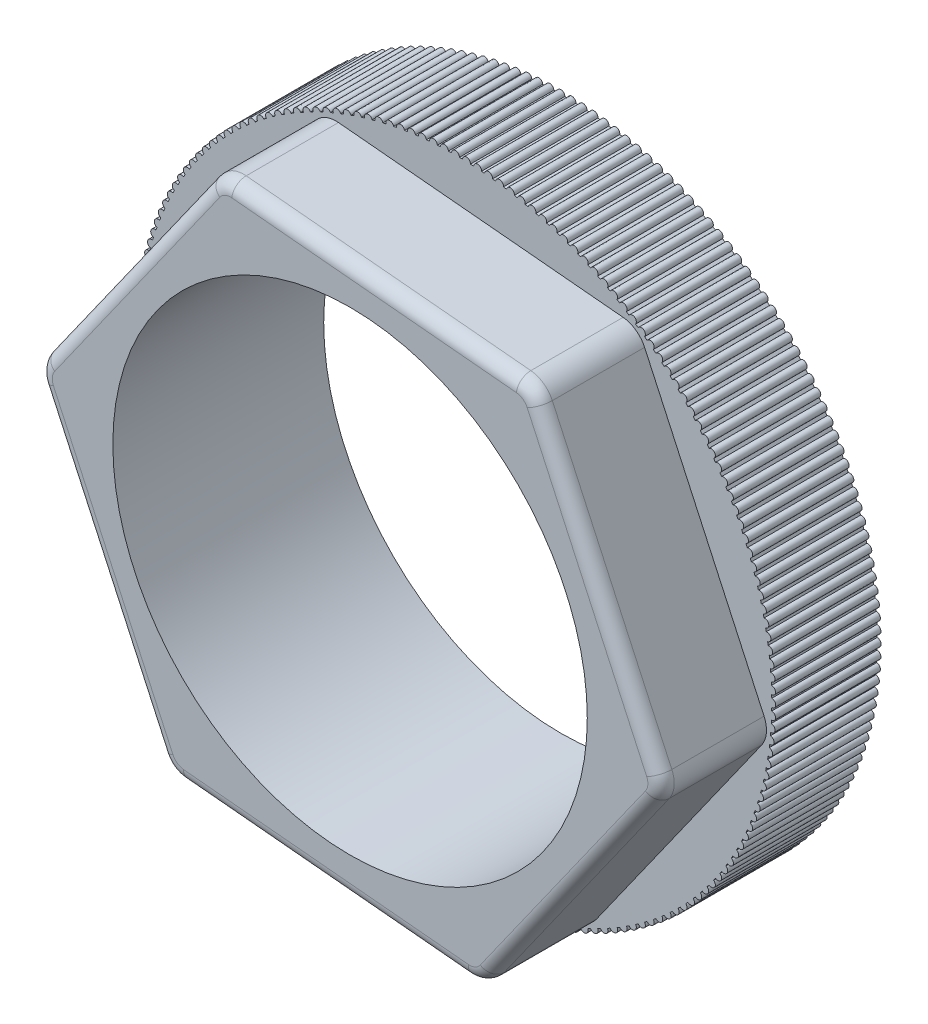
from build123d import *

# Parameters (mm, degrees)
CROQUIS1_R              = 12
CROQUIS1_R_2            = 9
SALIENTE_EXTRUIR1_DEPTH = 4
SALIENTE_EXTRUIR4_DEPTH = 4
CROQUIS3_R              = 9
SALIENTE_EXTRUIR5_DEPTH = 4
REDONDEO1_R             = 1
REDONDEO2_R             = 0.5


with BuildPart() as part:
    # Croquis1 → Saliente-Extruir1 (new body)
    with BuildSketch(Plane.XY):
        Circle(CROQUIS1_R)
        Circle(CROQUIS1_R_2, mode=Mode.SUBTRACT)
    extrude(amount=SALIENTE_EXTRUIR1_DEPTH)

    # Croquis2 → Saliente-Extruir4 (add)
    with BuildSketch(Plane.XY.offset(4)):
        with BuildLine():
            ThreePointArc((0.14999707, 11.9990625), (0, 12.15), (-0.14999707, 11.9990625))
            ThreePointArc((-0.14999707, 11.9990625), (0, 12), (0.14999707, 11.9990625))
        make_face()
        with BuildLine():
            ThreePointArc((0.568666938, 11.986518173), (0.41879396, 11.992689924), (0.268855546, 11.996987818))
            ThreePointArc((0.268855546, 11.996987818), (0.424028885, 12.142598548), (0.568666938, 11.986518173))
        make_face()
        with BuildLine():
            ThreePointArc((0.986643973, 11.95937012), (0.837077685, 11.970768603), (0.687380603, 11.980296654))
            ThreePointArc((0.687380603, 11.980296654), (0.847541156, 12.120403211), (0.986643973, 11.95937012))
        make_face()
        with BuildLine():
            ThreePointArc((1.403418934, 11.917651417), (1.254341559, 11.934262744), (1.105068193, 11.949009343))
            ThreePointArc((1.105068193, 11.949009343), (1.270020829, 12.083441029), (1.403418934, 11.917651417))
        make_face()
        with BuildLine():
            ThreePointArc((1.818484046, 11.861412891), (1.670077212, 11.883216825), (1.521409428, 11.903164006))
            ThreePointArc((1.521409428, 11.903164006), (1.690953177, 12.031757035), (1.818484046, 11.861412891))
        make_face()
        with BuildLine():
            ThreePointArc((2.231333615, 11.790723061), (2.083778132, 11.817693036), (1.935897059, 11.842816497))
            ThreePointArc((1.935897059, 11.842816497), (2.109825359, 11.965414199), (2.231333615, 11.790723061))
        make_face()
        with BuildLine():
            ThreePointArc((2.641464647, 11.705668051), (2.49494029, 11.737771209), (2.348026098, 11.76804034))
            ThreePointArc((2.348026098, 11.76804034), (2.526127043, 11.884493349), (2.641464647, 11.705668051))
        make_face()
        with BuildLine():
            ThreePointArc((3.048377462, 11.606351487), (2.903062747, 11.643548715), (2.757294429, 11.678926639))
            ThreePointArc((2.757294429, 11.678926639), (2.939351032, 11.789093074), (3.048377462, 11.606351487))
        make_face()
        with BuildLine():
            ThreePointArc((3.451576298, 11.492894373), (3.30764827, 11.535140351), (3.163203422, 11.575583964))
            ThreePointArc((3.163203422, 11.575583964), (3.348993873, 11.679329606), (3.451576298, 11.492894373))
        make_face()
        with BuildLine():
            ThreePointArc((3.85056992, 11.365434936), (3.708203932, 11.412678196), (3.565258538, 11.458138224))
            ThreePointArc((3.565258538, 11.458138224), (3.754556482, 11.555336673), (3.85056992, 11.365434936))
        make_face()
        with BuildLine():
            ThreePointArc((4.244872216, 11.224128468), (4.10424172, 11.276311449), (3.962969936, 11.326732507))
            ThreePointArc((3.962969936, 11.326732507), (4.155544741, 11.417265343), (4.244872216, 11.224128468))
        make_face()
        with BuildLine():
            ThreePointArc((4.634002789, 11.069147128), (4.495279121, 11.126206255), (4.355853066, 11.181526911))
            ThreePointArc((4.355853066, 11.181526911), (4.55147011, 11.265283833), (4.634002789, 11.069147128))
        make_face()
        with BuildLine():
            ThreePointArc((5.017487544, 10.900679738), (4.880839717, 10.962545492), (4.743429259, 11.022698348))
            ThreePointArc((4.743429259, 11.022698348), (4.941850213, 11.09957731), (5.017487544, 10.900679738))
        make_face()
        with BuildLine():
            ThreePointArc((5.394859262, 10.718931548), (5.260453761, 10.785528556), (5.125226315, 10.850440324))
            ThreePointArc((5.125226315, 10.850440324), (5.326209433, 10.920347663), (5.394859262, 10.718931548))
        make_face()
        with BuildLine():
            ThreePointArc((5.765658176, 10.524123992), (5.633658753, 10.595371114), (5.500779072, 10.66496271))
            ThreePointArc((5.500779072, 10.66496271), (5.704079488, 10.727813253), (5.765658176, 10.524123992))
        make_face()
        with BuildLine():
            ThreePointArc((6.129432523, 10.316494411), (6, 10.392304845), (5.869629977, 10.466491482))
            ThreePointArc((5.869629977, 10.466491482), (6.075, 10.522208656), (6.129432523, 10.316494411))
        make_face()
        with BuildLine():
            ThreePointArc((6.485739101, 10.096295772), (6.359031171, 10.176577154), (6.231329642, 10.255268446))
            ThreePointArc((6.231329642, 10.255268446), (6.43851906, 10.303784368), (6.485739101, 10.096295772))
        make_face()
        with BuildLine():
            ThreePointArc((6.834143805, 9.863796351), (6.710314842, 9.948450871), (6.585437391, 10.031550945))
            ThreePointArc((6.585437391, 10.031550945), (6.794193777, 10.072806507), (6.834143805, 9.863796351))
        make_face()
        with BuildLine():
            ThreePointArc((7.174222158, 9.619279413), (7.053423028, 9.708203932), (6.9315218, 9.795611545))
            ThreePointArc((6.9315218, 9.795611545), (7.141590815, 9.829556482), (7.174222158, 9.619279413))
        make_face()
        with BuildLine():
            ThreePointArc((7.505559826, 9.363042866), (7.387937704, 9.456129043), (7.269161217, 9.547737701))
            ThreePointArc((7.269161217, 9.547737701), (7.480286925, 9.574330656), (7.505559826, 9.363042866))
        make_face()
        with BuildLine():
            ThreePointArc((7.827753125, 9.095398892), (7.713451316, 9.192533317), (7.597944281, 9.288231409))
            ThreePointArc((7.597944281, 9.288231409), (7.809869458, 9.307439984), (7.827753125, 9.095398892))
        make_face()
        with BuildLine():
            ThreePointArc((8.140409513, 8.816673577), (8.029567276, 8.917737906), (7.91747042, 9.017408838))
            ThreePointArc((7.91747042, 9.017408838), (8.129936867, 9.02920963), (8.140409513, 8.816673577))
        make_face()
        with BuildLine():
            ThreePointArc((8.443148066, 8.527206503), (8.335900446, 8.632077604), (8.227350341, 8.735599943))
            ThreePointArc((8.227350341, 8.735599943), (8.440099201, 8.739978574), (8.443148066, 8.527206503))
        make_face()
        with BuildLine():
            ThreePointArc((8.735599943, 8.227350341), (8.632077604, 8.335900446), (8.527206503, 8.443148066))
            ThreePointArc((8.527206503, 8.443148066), (8.739978574, 8.440099201), (8.735599943, 8.227350341))
        make_face()
        with BuildLine():
            ThreePointArc((9.017408838, 7.91747042), (8.917737906, 8.029567276), (8.816673577, 8.140409513))
            ThreePointArc((8.816673577, 8.140409513), (9.02920963, 8.129936867), (9.017408838, 7.91747042))
        make_face()
        with BuildLine():
            ThreePointArc((9.288231409, 7.597944281), (9.192533317, 7.713451316), (9.095398892, 7.827753125))
            ThreePointArc((9.095398892, 7.827753125), (9.307439984, 7.809869458), (9.288231409, 7.597944281))
        make_face()
        with BuildLine():
            ThreePointArc((9.547737701, 7.269161217), (9.456129043, 7.387937704), (9.363042866, 7.505559826))
            ThreePointArc((9.363042866, 7.505559826), (9.574330656, 7.480286925), (9.547737701, 7.269161217))
        make_face()
        with BuildLine():
            ThreePointArc((9.795611545, 6.9315218), (9.708203932, 7.053423028), (9.619279413, 7.174222158))
            ThreePointArc((9.619279413, 7.174222158), (9.829556482, 7.141590815), (9.795611545, 6.9315218))
        make_face()
        with BuildLine():
            ThreePointArc((10.031550945, 6.585437391), (9.948450871, 6.710314842), (9.863796351, 6.834143805))
            ThreePointArc((9.863796351, 6.834143805), (10.072806507, 6.794193777), (10.031550945, 6.585437391))
        make_face()
        with BuildLine():
            ThreePointArc((10.255268446, 6.231329642), (10.176577154, 6.359031171), (10.096295772, 6.485739101))
            ThreePointArc((10.096295772, 6.485739101), (10.303784368, 6.43851906), (10.255268446, 6.231329642))
        make_face()
        with BuildLine():
            ThreePointArc((10.466491482, 5.869629977), (10.392304845, 6), (10.316494411, 6.129432523))
            ThreePointArc((10.316494411, 6.129432523), (10.522208656, 6.075), (10.466491482, 5.869629977))
        make_face()
        with BuildLine():
            ThreePointArc((10.66496271, 5.500779072), (10.595371114, 5.633658753), (10.524123992, 5.765658176))
            ThreePointArc((10.524123992, 5.765658176), (10.727813253, 5.704079488), (10.66496271, 5.500779072))
        make_face()
        with BuildLine():
            ThreePointArc((10.850440324, 5.125226315), (10.785528556, 5.260453761), (10.718931548, 5.394859262))
            ThreePointArc((10.718931548, 5.394859262), (10.920347663, 5.326209433), (10.850440324, 5.125226315))
        make_face()
        with BuildLine():
            ThreePointArc((11.022698348, 4.743429259), (10.962545492, 4.880839717), (10.900679738, 5.017487544))
            ThreePointArc((10.900679738, 5.017487544), (11.09957731, 4.941850213), (11.022698348, 4.743429259))
        make_face()
        with BuildLine():
            ThreePointArc((11.181526911, 4.355853066), (11.126206255, 4.495279121), (11.069147128, 4.634002789))
            ThreePointArc((11.069147128, 4.634002789), (11.265283833, 4.55147011), (11.181526911, 4.355853066))
        make_face()
        with BuildLine():
            ThreePointArc((11.326732507, 3.962969936), (11.276311449, 4.10424172), (11.224128468, 4.244872216))
            ThreePointArc((11.224128468, 4.244872216), (11.417265343, 4.155544741), (11.326732507, 3.962969936))
        make_face()
        with BuildLine():
            ThreePointArc((11.458138224, 3.565258538), (11.412678196, 3.708203932), (11.365434936, 3.85056992))
            ThreePointArc((11.365434936, 3.85056992), (11.555336673, 3.754556482), (11.458138224, 3.565258538))
        make_face()
        with BuildLine():
            ThreePointArc((11.575583964, 3.163203422), (11.535140351, 3.30764827), (11.492894373, 3.451576298))
            ThreePointArc((11.492894373, 3.451576298), (11.679329606, 3.348993873), (11.575583964, 3.163203422))
        make_face()
        with BuildLine():
            ThreePointArc((11.678926639, 2.757294429), (11.643548715, 2.903062747), (11.606351487, 3.048377462))
            ThreePointArc((11.606351487, 3.048377462), (11.789093074, 2.939351032), (11.678926639, 2.757294429))
        make_face()
        with BuildLine():
            ThreePointArc((11.76804034, 2.348026098), (11.737771209, 2.49494029), (11.705668051, 2.641464647))
            ThreePointArc((11.705668051, 2.641464647), (11.884493349, 2.526127043), (11.76804034, 2.348026098))
        make_face()
        with BuildLine():
            ThreePointArc((11.842816497, 1.935897059), (11.817693036, 2.083778132), (11.790723061, 2.231333615))
            ThreePointArc((11.790723061, 2.231333615), (11.965414199, 2.109825359), (11.842816497, 1.935897059))
        make_face()
        with BuildLine():
            ThreePointArc((11.903164006, 1.521409428), (11.883216825, 1.670077212), (11.861412891, 1.818484046))
            ThreePointArc((11.861412891, 1.818484046), (12.031757035, 1.690953177), (11.903164006, 1.521409428))
        make_face()
        with BuildLine():
            ThreePointArc((11.949009343, 1.105068193), (11.934262744, 1.254341559), (11.917651417, 1.403418934))
            ThreePointArc((11.917651417, 1.403418934), (12.083441029, 1.270020829), (11.949009343, 1.105068193))
        make_face()
        with BuildLine():
            ThreePointArc((11.980296654, 0.687380603), (11.970768603, 0.837077685), (11.95937012, 0.986643973))
            ThreePointArc((11.95937012, 0.986643973), (12.120403211, 0.847541156), (11.980296654, 0.687380603))
        make_face()
        with BuildLine():
            ThreePointArc((11.996987818, 0.268855546), (11.992689924, 0.41879396), (11.986518173, 0.568666938))
            ThreePointArc((11.986518173, 0.568666938), (12.142598548, 0.424028885), (11.996987818, 0.268855546))
        make_face()
        with BuildLine():
            ThreePointArc((11.9990625, -0.14999707), (12, 0), (11.9990625, 0.14999707))
            ThreePointArc((11.9990625, 0.14999707), (12.15, 0), (11.9990625, -0.14999707))
        make_face()
        with BuildLine():
            ThreePointArc((11.986518173, -0.568666938), (11.992689924, -0.41879396), (11.996987818, -0.268855546))
            ThreePointArc((11.996987818, -0.268855546), (12.142598548, -0.424028885), (11.986518173, -0.568666938))
        make_face()
        with BuildLine():
            ThreePointArc((11.95937012, -0.986643973), (11.970768603, -0.837077685), (11.980296654, -0.687380603))
            ThreePointArc((11.980296654, -0.687380603), (12.120403211, -0.847541156), (11.95937012, -0.986643973))
        make_face()
        with BuildLine():
            ThreePointArc((11.917651417, -1.403418934), (11.934262744, -1.254341559), (11.949009343, -1.105068193))
            ThreePointArc((11.949009343, -1.105068193), (12.083441029, -1.270020829), (11.917651417, -1.403418934))
        make_face()
        with BuildLine():
            ThreePointArc((11.861412891, -1.818484046), (11.883216825, -1.670077212), (11.903164006, -1.521409428))
            ThreePointArc((11.903164006, -1.521409428), (12.031757035, -1.690953177), (11.861412891, -1.818484046))
        make_face()
        with BuildLine():
            ThreePointArc((11.790723061, -2.231333615), (11.817693036, -2.083778132), (11.842816497, -1.935897059))
            ThreePointArc((11.842816497, -1.935897059), (11.965414199, -2.109825359), (11.790723061, -2.231333615))
        make_face()
        with BuildLine():
            ThreePointArc((11.705668051, -2.641464647), (11.737771209, -2.49494029), (11.76804034, -2.348026098))
            ThreePointArc((11.76804034, -2.348026098), (11.884493349, -2.526127043), (11.705668051, -2.641464647))
        make_face()
        with BuildLine():
            ThreePointArc((11.606351487, -3.048377462), (11.643548715, -2.903062747), (11.678926639, -2.757294429))
            ThreePointArc((11.678926639, -2.757294429), (11.789093074, -2.939351032), (11.606351487, -3.048377462))
        make_face()
        with BuildLine():
            ThreePointArc((11.492894373, -3.451576298), (11.535140351, -3.30764827), (11.575583964, -3.163203422))
            ThreePointArc((11.575583964, -3.163203422), (11.679329606, -3.348993873), (11.492894373, -3.451576298))
        make_face()
        with BuildLine():
            ThreePointArc((11.365434936, -3.85056992), (11.412678196, -3.708203932), (11.458138224, -3.565258538))
            ThreePointArc((11.458138224, -3.565258538), (11.555336673, -3.754556482), (11.365434936, -3.85056992))
        make_face()
        with BuildLine():
            ThreePointArc((11.224128468, -4.244872216), (11.276311449, -4.10424172), (11.326732507, -3.962969936))
            ThreePointArc((11.326732507, -3.962969936), (11.417265343, -4.155544741), (11.224128468, -4.244872216))
        make_face()
        with BuildLine():
            ThreePointArc((11.069147128, -4.634002789), (11.126206255, -4.495279121), (11.181526911, -4.355853066))
            ThreePointArc((11.181526911, -4.355853066), (11.265283833, -4.55147011), (11.069147128, -4.634002789))
        make_face()
        with BuildLine():
            ThreePointArc((10.900679738, -5.017487544), (10.962545492, -4.880839717), (11.022698348, -4.743429259))
            ThreePointArc((11.022698348, -4.743429259), (11.09957731, -4.941850213), (10.900679738, -5.017487544))
        make_face()
        with BuildLine():
            ThreePointArc((10.718931548, -5.394859262), (10.785528556, -5.260453761), (10.850440324, -5.125226315))
            ThreePointArc((10.850440324, -5.125226315), (10.920347663, -5.326209433), (10.718931548, -5.394859262))
        make_face()
        with BuildLine():
            ThreePointArc((10.524123992, -5.765658176), (10.595371114, -5.633658753), (10.66496271, -5.500779072))
            ThreePointArc((10.66496271, -5.500779072), (10.727813253, -5.704079488), (10.524123992, -5.765658176))
        make_face()
        with BuildLine():
            ThreePointArc((10.316494411, -6.129432523), (10.392304845, -6), (10.466491482, -5.869629977))
            ThreePointArc((10.466491482, -5.869629977), (10.522208656, -6.075), (10.316494411, -6.129432523))
        make_face()
        with BuildLine():
            ThreePointArc((10.096295772, -6.485739101), (10.176577154, -6.359031171), (10.255268446, -6.231329642))
            ThreePointArc((10.255268446, -6.231329642), (10.303784368, -6.43851906), (10.096295772, -6.485739101))
        make_face()
        with BuildLine():
            ThreePointArc((9.863796351, -6.834143805), (9.948450871, -6.710314842), (10.031550945, -6.585437391))
            ThreePointArc((10.031550945, -6.585437391), (10.072806507, -6.794193777), (9.863796351, -6.834143805))
        make_face()
        with BuildLine():
            ThreePointArc((9.619279413, -7.174222158), (9.708203932, -7.053423028), (9.795611545, -6.9315218))
            ThreePointArc((9.795611545, -6.9315218), (9.829556482, -7.141590815), (9.619279413, -7.174222158))
        make_face()
        with BuildLine():
            ThreePointArc((9.363042866, -7.505559826), (9.456129043, -7.387937704), (9.547737701, -7.269161217))
            ThreePointArc((9.547737701, -7.269161217), (9.574330656, -7.480286925), (9.363042866, -7.505559826))
        make_face()
        with BuildLine():
            ThreePointArc((9.095398892, -7.827753125), (9.192533317, -7.713451316), (9.288231409, -7.597944281))
            ThreePointArc((9.288231409, -7.597944281), (9.307439984, -7.809869458), (9.095398892, -7.827753125))
        make_face()
        with BuildLine():
            ThreePointArc((8.816673577, -8.140409513), (8.917737906, -8.029567276), (9.017408838, -7.91747042))
            ThreePointArc((9.017408838, -7.91747042), (9.02920963, -8.129936867), (8.816673577, -8.140409513))
        make_face()
        with BuildLine():
            ThreePointArc((8.527206503, -8.443148066), (8.632077604, -8.335900446), (8.735599943, -8.227350341))
            ThreePointArc((8.735599943, -8.227350341), (8.739978574, -8.440099201), (8.527206503, -8.443148066))
        make_face()
        with BuildLine():
            ThreePointArc((8.227350341, -8.735599943), (8.335900446, -8.632077604), (8.443148066, -8.527206503))
            ThreePointArc((8.443148066, -8.527206503), (8.440099201, -8.739978574), (8.227350341, -8.735599943))
        make_face()
        with BuildLine():
            ThreePointArc((7.91747042, -9.017408838), (8.029567276, -8.917737906), (8.140409513, -8.816673577))
            ThreePointArc((8.140409513, -8.816673577), (8.129936867, -9.02920963), (7.91747042, -9.017408838))
        make_face()
        with BuildLine():
            ThreePointArc((7.597944281, -9.288231409), (7.713451316, -9.192533317), (7.827753125, -9.095398892))
            ThreePointArc((7.827753125, -9.095398892), (7.809869458, -9.307439984), (7.597944281, -9.288231409))
        make_face()
        with BuildLine():
            ThreePointArc((7.269161217, -9.547737701), (7.387937704, -9.456129043), (7.505559826, -9.363042866))
            ThreePointArc((7.505559826, -9.363042866), (7.480286925, -9.574330656), (7.269161217, -9.547737701))
        make_face()
        with BuildLine():
            ThreePointArc((6.9315218, -9.795611545), (7.053423028, -9.708203932), (7.174222158, -9.619279413))
            ThreePointArc((7.174222158, -9.619279413), (7.141590815, -9.829556482), (6.9315218, -9.795611545))
        make_face()
        with BuildLine():
            ThreePointArc((6.585437391, -10.031550945), (6.710314842, -9.948450871), (6.834143805, -9.863796351))
            ThreePointArc((6.834143805, -9.863796351), (6.794193777, -10.072806507), (6.585437391, -10.031550945))
        make_face()
        with BuildLine():
            ThreePointArc((6.231329642, -10.255268446), (6.359031171, -10.176577154), (6.485739101, -10.096295772))
            ThreePointArc((6.485739101, -10.096295772), (6.43851906, -10.303784368), (6.231329642, -10.255268446))
        make_face()
        with BuildLine():
            ThreePointArc((5.869629977, -10.466491482), (6, -10.392304845), (6.129432523, -10.316494411))
            ThreePointArc((6.129432523, -10.316494411), (6.075, -10.522208656), (5.869629977, -10.466491482))
        make_face()
        with BuildLine():
            ThreePointArc((5.500779072, -10.66496271), (5.633658753, -10.595371114), (5.765658176, -10.524123992))
            ThreePointArc((5.765658176, -10.524123992), (5.704079488, -10.727813253), (5.500779072, -10.66496271))
        make_face()
        with BuildLine():
            ThreePointArc((5.125226315, -10.850440324), (5.260453761, -10.785528556), (5.394859262, -10.718931548))
            ThreePointArc((5.394859262, -10.718931548), (5.326209433, -10.920347663), (5.125226315, -10.850440324))
        make_face()
        with BuildLine():
            ThreePointArc((4.743429259, -11.022698348), (4.880839717, -10.962545492), (5.017487544, -10.900679738))
            ThreePointArc((5.017487544, -10.900679738), (4.941850213, -11.09957731), (4.743429259, -11.022698348))
        make_face()
        with BuildLine():
            ThreePointArc((4.355853066, -11.181526911), (4.495279121, -11.126206255), (4.634002789, -11.069147128))
            ThreePointArc((4.634002789, -11.069147128), (4.55147011, -11.265283833), (4.355853066, -11.181526911))
        make_face()
        with BuildLine():
            ThreePointArc((3.962969936, -11.326732507), (4.10424172, -11.276311449), (4.244872216, -11.224128468))
            ThreePointArc((4.244872216, -11.224128468), (4.155544741, -11.417265343), (3.962969936, -11.326732507))
        make_face()
        with BuildLine():
            ThreePointArc((3.565258538, -11.458138224), (3.708203932, -11.412678196), (3.85056992, -11.365434936))
            ThreePointArc((3.85056992, -11.365434936), (3.754556482, -11.555336673), (3.565258538, -11.458138224))
        make_face()
        with BuildLine():
            ThreePointArc((3.163203422, -11.575583964), (3.30764827, -11.535140351), (3.451576298, -11.492894373))
            ThreePointArc((3.451576298, -11.492894373), (3.348993873, -11.679329606), (3.163203422, -11.575583964))
        make_face()
        with BuildLine():
            ThreePointArc((2.757294429, -11.678926639), (2.903062747, -11.643548715), (3.048377462, -11.606351487))
            ThreePointArc((3.048377462, -11.606351487), (2.939351032, -11.789093074), (2.757294429, -11.678926639))
        make_face()
        with BuildLine():
            ThreePointArc((2.348026098, -11.76804034), (2.49494029, -11.737771209), (2.641464647, -11.705668051))
            ThreePointArc((2.641464647, -11.705668051), (2.526127043, -11.884493349), (2.348026098, -11.76804034))
        make_face()
        with BuildLine():
            ThreePointArc((1.935897059, -11.842816497), (2.083778132, -11.817693036), (2.231333615, -11.790723061))
            ThreePointArc((2.231333615, -11.790723061), (2.109825359, -11.965414199), (1.935897059, -11.842816497))
        make_face()
        with BuildLine():
            ThreePointArc((1.521409428, -11.903164006), (1.670077212, -11.883216825), (1.818484046, -11.861412891))
            ThreePointArc((1.818484046, -11.861412891), (1.690953177, -12.031757035), (1.521409428, -11.903164006))
        make_face()
        with BuildLine():
            ThreePointArc((1.105068193, -11.949009343), (1.254341559, -11.934262744), (1.403418934, -11.917651417))
            ThreePointArc((1.403418934, -11.917651417), (1.270020829, -12.083441029), (1.105068193, -11.949009343))
        make_face()
        with BuildLine():
            ThreePointArc((0.687380603, -11.980296654), (0.837077685, -11.970768603), (0.986643973, -11.95937012))
            ThreePointArc((0.986643973, -11.95937012), (0.847541156, -12.120403211), (0.687380603, -11.980296654))
        make_face()
        with BuildLine():
            ThreePointArc((0.268855546, -11.996987818), (0.41879396, -11.992689924), (0.568666938, -11.986518173))
            ThreePointArc((0.568666938, -11.986518173), (0.424028885, -12.142598548), (0.268855546, -11.996987818))
        make_face()
        with BuildLine():
            ThreePointArc((-0.14999707, -11.9990625), (0, -12), (0.14999707, -11.9990625))
            ThreePointArc((0.14999707, -11.9990625), (0, -12.15), (-0.14999707, -11.9990625))
        make_face()
        with BuildLine():
            ThreePointArc((-0.568666938, -11.986518173), (-0.41879396, -11.992689924), (-0.268855546, -11.996987818))
            ThreePointArc((-0.268855546, -11.996987818), (-0.424028885, -12.142598548), (-0.568666938, -11.986518173))
        make_face()
        with BuildLine():
            ThreePointArc((-0.986643973, -11.95937012), (-0.837077685, -11.970768603), (-0.687380603, -11.980296654))
            ThreePointArc((-0.687380603, -11.980296654), (-0.847541156, -12.120403211), (-0.986643973, -11.95937012))
        make_face()
        with BuildLine():
            ThreePointArc((-1.403418934, -11.917651417), (-1.254341559, -11.934262744), (-1.105068193, -11.949009343))
            ThreePointArc((-1.105068193, -11.949009343), (-1.270020829, -12.083441029), (-1.403418934, -11.917651417))
        make_face()
        with BuildLine():
            ThreePointArc((-1.818484046, -11.861412891), (-1.670077212, -11.883216825), (-1.521409428, -11.903164006))
            ThreePointArc((-1.521409428, -11.903164006), (-1.690953177, -12.031757035), (-1.818484046, -11.861412891))
        make_face()
        with BuildLine():
            ThreePointArc((-2.231333615, -11.790723061), (-2.083778132, -11.817693036), (-1.935897059, -11.842816497))
            ThreePointArc((-1.935897059, -11.842816497), (-2.109825359, -11.965414199), (-2.231333615, -11.790723061))
        make_face()
        with BuildLine():
            ThreePointArc((-2.641464647, -11.705668051), (-2.49494029, -11.737771209), (-2.348026098, -11.76804034))
            ThreePointArc((-2.348026098, -11.76804034), (-2.526127043, -11.884493349), (-2.641464647, -11.705668051))
        make_face()
        with BuildLine():
            ThreePointArc((-3.048377462, -11.606351487), (-2.903062747, -11.643548715), (-2.757294429, -11.678926639))
            ThreePointArc((-2.757294429, -11.678926639), (-2.939351032, -11.789093074), (-3.048377462, -11.606351487))
        make_face()
        with BuildLine():
            ThreePointArc((-3.451576298, -11.492894373), (-3.30764827, -11.535140351), (-3.163203422, -11.575583964))
            ThreePointArc((-3.163203422, -11.575583964), (-3.348993873, -11.679329606), (-3.451576298, -11.492894373))
        make_face()
        with BuildLine():
            ThreePointArc((-3.85056992, -11.365434936), (-3.708203932, -11.412678196), (-3.565258538, -11.458138224))
            ThreePointArc((-3.565258538, -11.458138224), (-3.754556482, -11.555336673), (-3.85056992, -11.365434936))
        make_face()
        with BuildLine():
            ThreePointArc((-4.244872216, -11.224128468), (-4.10424172, -11.276311449), (-3.962969936, -11.326732507))
            ThreePointArc((-3.962969936, -11.326732507), (-4.155544741, -11.417265343), (-4.244872216, -11.224128468))
        make_face()
        with BuildLine():
            ThreePointArc((-4.634002789, -11.069147128), (-4.495279121, -11.126206255), (-4.355853066, -11.181526911))
            ThreePointArc((-4.355853066, -11.181526911), (-4.55147011, -11.265283833), (-4.634002789, -11.069147128))
        make_face()
        with BuildLine():
            ThreePointArc((-5.017487544, -10.900679738), (-4.880839717, -10.962545492), (-4.743429259, -11.022698348))
            ThreePointArc((-4.743429259, -11.022698348), (-4.941850213, -11.09957731), (-5.017487544, -10.900679738))
        make_face()
        with BuildLine():
            ThreePointArc((-5.394859262, -10.718931548), (-5.260453761, -10.785528556), (-5.125226315, -10.850440324))
            ThreePointArc((-5.125226315, -10.850440324), (-5.326209433, -10.920347663), (-5.394859262, -10.718931548))
        make_face()
        with BuildLine():
            ThreePointArc((-5.765658176, -10.524123992), (-5.633658753, -10.595371114), (-5.500779072, -10.66496271))
            ThreePointArc((-5.500779072, -10.66496271), (-5.704079488, -10.727813253), (-5.765658176, -10.524123992))
        make_face()
        with BuildLine():
            ThreePointArc((-6.129432523, -10.316494411), (-6, -10.392304845), (-5.869629977, -10.466491482))
            ThreePointArc((-5.869629977, -10.466491482), (-6.075, -10.522208656), (-6.129432523, -10.316494411))
        make_face()
        with BuildLine():
            ThreePointArc((-6.485739101, -10.096295772), (-6.359031171, -10.176577154), (-6.231329642, -10.255268446))
            ThreePointArc((-6.231329642, -10.255268446), (-6.43851906, -10.303784368), (-6.485739101, -10.096295772))
        make_face()
        with BuildLine():
            ThreePointArc((-6.834143805, -9.863796351), (-6.710314842, -9.948450871), (-6.585437391, -10.031550945))
            ThreePointArc((-6.585437391, -10.031550945), (-6.794193777, -10.072806507), (-6.834143805, -9.863796351))
        make_face()
        with BuildLine():
            ThreePointArc((-7.174222158, -9.619279413), (-7.053423028, -9.708203932), (-6.9315218, -9.795611545))
            ThreePointArc((-6.9315218, -9.795611545), (-7.141590815, -9.829556482), (-7.174222158, -9.619279413))
        make_face()
        with BuildLine():
            ThreePointArc((-7.505559826, -9.363042866), (-7.387937704, -9.456129043), (-7.269161217, -9.547737701))
            ThreePointArc((-7.269161217, -9.547737701), (-7.480286925, -9.574330656), (-7.505559826, -9.363042866))
        make_face()
        with BuildLine():
            ThreePointArc((-7.827753125, -9.095398892), (-7.713451316, -9.192533317), (-7.597944281, -9.288231409))
            ThreePointArc((-7.597944281, -9.288231409), (-7.809869458, -9.307439984), (-7.827753125, -9.095398892))
        make_face()
        with BuildLine():
            ThreePointArc((-8.140409513, -8.816673577), (-8.029567276, -8.917737906), (-7.91747042, -9.017408838))
            ThreePointArc((-7.91747042, -9.017408838), (-8.129936867, -9.02920963), (-8.140409513, -8.816673577))
        make_face()
        with BuildLine():
            ThreePointArc((-8.443148066, -8.527206503), (-8.335900446, -8.632077604), (-8.227350341, -8.735599943))
            ThreePointArc((-8.227350341, -8.735599943), (-8.440099201, -8.739978574), (-8.443148066, -8.527206503))
        make_face()
        with BuildLine():
            ThreePointArc((-8.735599943, -8.227350341), (-8.632077604, -8.335900446), (-8.527206503, -8.443148066))
            ThreePointArc((-8.527206503, -8.443148066), (-8.739978574, -8.440099201), (-8.735599943, -8.227350341))
        make_face()
        with BuildLine():
            ThreePointArc((-9.017408838, -7.91747042), (-8.917737906, -8.029567276), (-8.816673577, -8.140409513))
            ThreePointArc((-8.816673577, -8.140409513), (-9.02920963, -8.129936867), (-9.017408838, -7.91747042))
        make_face()
        with BuildLine():
            ThreePointArc((-9.288231409, -7.597944281), (-9.192533317, -7.713451316), (-9.095398892, -7.827753125))
            ThreePointArc((-9.095398892, -7.827753125), (-9.307439984, -7.809869458), (-9.288231409, -7.597944281))
        make_face()
        with BuildLine():
            ThreePointArc((-9.547737701, -7.269161217), (-9.456129043, -7.387937704), (-9.363042866, -7.505559826))
            ThreePointArc((-9.363042866, -7.505559826), (-9.574330656, -7.480286925), (-9.547737701, -7.269161217))
        make_face()
        with BuildLine():
            ThreePointArc((-9.795611545, -6.9315218), (-9.708203932, -7.053423028), (-9.619279413, -7.174222158))
            ThreePointArc((-9.619279413, -7.174222158), (-9.829556482, -7.141590815), (-9.795611545, -6.9315218))
        make_face()
        with BuildLine():
            ThreePointArc((-10.031550945, -6.585437391), (-9.948450871, -6.710314842), (-9.863796351, -6.834143805))
            ThreePointArc((-9.863796351, -6.834143805), (-10.072806507, -6.794193777), (-10.031550945, -6.585437391))
        make_face()
        with BuildLine():
            ThreePointArc((-10.255268446, -6.231329642), (-10.176577154, -6.359031171), (-10.096295772, -6.485739101))
            ThreePointArc((-10.096295772, -6.485739101), (-10.303784368, -6.43851906), (-10.255268446, -6.231329642))
        make_face()
        with BuildLine():
            ThreePointArc((-10.466491482, -5.869629977), (-10.392304845, -6), (-10.316494411, -6.129432523))
            ThreePointArc((-10.316494411, -6.129432523), (-10.522208656, -6.075), (-10.466491482, -5.869629977))
        make_face()
        with BuildLine():
            ThreePointArc((-10.66496271, -5.500779072), (-10.595371114, -5.633658753), (-10.524123992, -5.765658176))
            ThreePointArc((-10.524123992, -5.765658176), (-10.727813253, -5.704079488), (-10.66496271, -5.500779072))
        make_face()
        with BuildLine():
            ThreePointArc((-10.850440324, -5.125226315), (-10.785528556, -5.260453761), (-10.718931548, -5.394859262))
            ThreePointArc((-10.718931548, -5.394859262), (-10.920347663, -5.326209433), (-10.850440324, -5.125226315))
        make_face()
        with BuildLine():
            ThreePointArc((-11.022698348, -4.743429259), (-10.962545492, -4.880839717), (-10.900679738, -5.017487544))
            ThreePointArc((-10.900679738, -5.017487544), (-11.09957731, -4.941850213), (-11.022698348, -4.743429259))
        make_face()
        with BuildLine():
            ThreePointArc((-11.181526911, -4.355853066), (-11.126206255, -4.495279121), (-11.069147128, -4.634002789))
            ThreePointArc((-11.069147128, -4.634002789), (-11.265283833, -4.55147011), (-11.181526911, -4.355853066))
        make_face()
        with BuildLine():
            ThreePointArc((-11.326732507, -3.962969936), (-11.276311449, -4.10424172), (-11.224128468, -4.244872216))
            ThreePointArc((-11.224128468, -4.244872216), (-11.417265343, -4.155544741), (-11.326732507, -3.962969936))
        make_face()
        with BuildLine():
            ThreePointArc((-11.458138224, -3.565258538), (-11.412678196, -3.708203932), (-11.365434936, -3.85056992))
            ThreePointArc((-11.365434936, -3.85056992), (-11.555336673, -3.754556482), (-11.458138224, -3.565258538))
        make_face()
        with BuildLine():
            ThreePointArc((-11.575583964, -3.163203422), (-11.535140351, -3.30764827), (-11.492894373, -3.451576298))
            ThreePointArc((-11.492894373, -3.451576298), (-11.679329606, -3.348993873), (-11.575583964, -3.163203422))
        make_face()
        with BuildLine():
            ThreePointArc((-11.678926639, -2.757294429), (-11.643548715, -2.903062747), (-11.606351487, -3.048377462))
            ThreePointArc((-11.606351487, -3.048377462), (-11.789093074, -2.939351032), (-11.678926639, -2.757294429))
        make_face()
        with BuildLine():
            ThreePointArc((-11.76804034, -2.348026098), (-11.737771209, -2.49494029), (-11.705668051, -2.641464647))
            ThreePointArc((-11.705668051, -2.641464647), (-11.884493349, -2.526127043), (-11.76804034, -2.348026098))
        make_face()
        with BuildLine():
            ThreePointArc((-11.842816497, -1.935897059), (-11.817693036, -2.083778132), (-11.790723061, -2.231333615))
            ThreePointArc((-11.790723061, -2.231333615), (-11.965414199, -2.109825359), (-11.842816497, -1.935897059))
        make_face()
        with BuildLine():
            ThreePointArc((-11.903164006, -1.521409428), (-11.883216825, -1.670077212), (-11.861412891, -1.818484046))
            ThreePointArc((-11.861412891, -1.818484046), (-12.031757035, -1.690953177), (-11.903164006, -1.521409428))
        make_face()
        with BuildLine():
            ThreePointArc((-11.949009343, -1.105068193), (-11.934262744, -1.254341559), (-11.917651417, -1.403418934))
            ThreePointArc((-11.917651417, -1.403418934), (-12.083441029, -1.270020829), (-11.949009343, -1.105068193))
        make_face()
        with BuildLine():
            ThreePointArc((-11.980296654, -0.687380603), (-11.970768603, -0.837077685), (-11.95937012, -0.986643973))
            ThreePointArc((-11.95937012, -0.986643973), (-12.120403211, -0.847541156), (-11.980296654, -0.687380603))
        make_face()
        with BuildLine():
            ThreePointArc((-11.996987818, -0.268855546), (-11.992689924, -0.41879396), (-11.986518173, -0.568666938))
            ThreePointArc((-11.986518173, -0.568666938), (-12.142598548, -0.424028885), (-11.996987818, -0.268855546))
        make_face()
        with BuildLine():
            ThreePointArc((-11.9990625, 0.14999707), (-12, 0), (-11.9990625, -0.14999707))
            ThreePointArc((-11.9990625, -0.14999707), (-12.15, 0), (-11.9990625, 0.14999707))
        make_face()
        with BuildLine():
            ThreePointArc((-11.986518173, 0.568666938), (-11.992689924, 0.41879396), (-11.996987818, 0.268855546))
            ThreePointArc((-11.996987818, 0.268855546), (-12.142598548, 0.424028885), (-11.986518173, 0.568666938))
        make_face()
        with BuildLine():
            ThreePointArc((-11.95937012, 0.986643973), (-11.970768603, 0.837077685), (-11.980296654, 0.687380603))
            ThreePointArc((-11.980296654, 0.687380603), (-12.120403211, 0.847541156), (-11.95937012, 0.986643973))
        make_face()
        with BuildLine():
            ThreePointArc((-11.917651417, 1.403418934), (-11.934262744, 1.254341559), (-11.949009343, 1.105068193))
            ThreePointArc((-11.949009343, 1.105068193), (-12.083441029, 1.270020829), (-11.917651417, 1.403418934))
        make_face()
        with BuildLine():
            ThreePointArc((-11.861412891, 1.818484046), (-11.883216825, 1.670077212), (-11.903164006, 1.521409428))
            ThreePointArc((-11.903164006, 1.521409428), (-12.031757035, 1.690953177), (-11.861412891, 1.818484046))
        make_face()
        with BuildLine():
            ThreePointArc((-11.790723061, 2.231333615), (-11.817693036, 2.083778132), (-11.842816497, 1.935897059))
            ThreePointArc((-11.842816497, 1.935897059), (-11.965414199, 2.109825359), (-11.790723061, 2.231333615))
        make_face()
        with BuildLine():
            ThreePointArc((-11.705668051, 2.641464647), (-11.737771209, 2.49494029), (-11.76804034, 2.348026098))
            ThreePointArc((-11.76804034, 2.348026098), (-11.884493349, 2.526127043), (-11.705668051, 2.641464647))
        make_face()
        with BuildLine():
            ThreePointArc((-11.606351487, 3.048377462), (-11.643548715, 2.903062747), (-11.678926639, 2.757294429))
            ThreePointArc((-11.678926639, 2.757294429), (-11.789093074, 2.939351032), (-11.606351487, 3.048377462))
        make_face()
        with BuildLine():
            ThreePointArc((-11.492894373, 3.451576298), (-11.535140351, 3.30764827), (-11.575583964, 3.163203422))
            ThreePointArc((-11.575583964, 3.163203422), (-11.679329606, 3.348993873), (-11.492894373, 3.451576298))
        make_face()
        with BuildLine():
            ThreePointArc((-11.365434936, 3.85056992), (-11.412678196, 3.708203932), (-11.458138224, 3.565258538))
            ThreePointArc((-11.458138224, 3.565258538), (-11.555336673, 3.754556482), (-11.365434936, 3.85056992))
        make_face()
        with BuildLine():
            ThreePointArc((-11.224128468, 4.244872216), (-11.276311449, 4.10424172), (-11.326732507, 3.962969936))
            ThreePointArc((-11.326732507, 3.962969936), (-11.417265343, 4.155544741), (-11.224128468, 4.244872216))
        make_face()
        with BuildLine():
            ThreePointArc((-11.069147128, 4.634002789), (-11.126206255, 4.495279121), (-11.181526911, 4.355853066))
            ThreePointArc((-11.181526911, 4.355853066), (-11.265283833, 4.55147011), (-11.069147128, 4.634002789))
        make_face()
        with BuildLine():
            ThreePointArc((-10.900679738, 5.017487544), (-10.962545492, 4.880839717), (-11.022698348, 4.743429259))
            ThreePointArc((-11.022698348, 4.743429259), (-11.09957731, 4.941850213), (-10.900679738, 5.017487544))
        make_face()
        with BuildLine():
            ThreePointArc((-10.718931548, 5.394859262), (-10.785528556, 5.260453761), (-10.850440324, 5.125226315))
            ThreePointArc((-10.850440324, 5.125226315), (-10.920347663, 5.326209433), (-10.718931548, 5.394859262))
        make_face()
        with BuildLine():
            ThreePointArc((-10.524123992, 5.765658176), (-10.595371114, 5.633658753), (-10.66496271, 5.500779072))
            ThreePointArc((-10.66496271, 5.500779072), (-10.727813253, 5.704079488), (-10.524123992, 5.765658176))
        make_face()
        with BuildLine():
            ThreePointArc((-10.316494411, 6.129432523), (-10.392304845, 6), (-10.466491482, 5.869629977))
            ThreePointArc((-10.466491482, 5.869629977), (-10.522208656, 6.075), (-10.316494411, 6.129432523))
        make_face()
        with BuildLine():
            ThreePointArc((-10.096295772, 6.485739101), (-10.176577154, 6.359031171), (-10.255268446, 6.231329642))
            ThreePointArc((-10.255268446, 6.231329642), (-10.303784368, 6.43851906), (-10.096295772, 6.485739101))
        make_face()
        with BuildLine():
            ThreePointArc((-9.863796351, 6.834143805), (-9.948450871, 6.710314842), (-10.031550945, 6.585437391))
            ThreePointArc((-10.031550945, 6.585437391), (-10.072806507, 6.794193777), (-9.863796351, 6.834143805))
        make_face()
        with BuildLine():
            ThreePointArc((-9.619279413, 7.174222158), (-9.708203932, 7.053423028), (-9.795611545, 6.9315218))
            ThreePointArc((-9.795611545, 6.9315218), (-9.829556482, 7.141590815), (-9.619279413, 7.174222158))
        make_face()
        with BuildLine():
            ThreePointArc((-9.363042866, 7.505559826), (-9.456129043, 7.387937704), (-9.547737701, 7.269161217))
            ThreePointArc((-9.547737701, 7.269161217), (-9.574330656, 7.480286925), (-9.363042866, 7.505559826))
        make_face()
        with BuildLine():
            ThreePointArc((-9.095398892, 7.827753125), (-9.192533317, 7.713451316), (-9.288231409, 7.597944281))
            ThreePointArc((-9.288231409, 7.597944281), (-9.307439984, 7.809869458), (-9.095398892, 7.827753125))
        make_face()
        with BuildLine():
            ThreePointArc((-8.816673577, 8.140409513), (-8.917737906, 8.029567276), (-9.017408838, 7.91747042))
            ThreePointArc((-9.017408838, 7.91747042), (-9.02920963, 8.129936867), (-8.816673577, 8.140409513))
        make_face()
        with BuildLine():
            ThreePointArc((-8.527206503, 8.443148066), (-8.632077604, 8.335900446), (-8.735599943, 8.227350341))
            ThreePointArc((-8.735599943, 8.227350341), (-8.739978574, 8.440099201), (-8.527206503, 8.443148066))
        make_face()
        with BuildLine():
            ThreePointArc((-8.227350341, 8.735599943), (-8.335900446, 8.632077604), (-8.443148066, 8.527206503))
            ThreePointArc((-8.443148066, 8.527206503), (-8.440099201, 8.739978574), (-8.227350341, 8.735599943))
        make_face()
        with BuildLine():
            ThreePointArc((-7.91747042, 9.017408838), (-8.029567276, 8.917737906), (-8.140409513, 8.816673577))
            ThreePointArc((-8.140409513, 8.816673577), (-8.129936867, 9.02920963), (-7.91747042, 9.017408838))
        make_face()
        with BuildLine():
            ThreePointArc((-7.597944281, 9.288231409), (-7.713451316, 9.192533317), (-7.827753125, 9.095398892))
            ThreePointArc((-7.827753125, 9.095398892), (-7.809869458, 9.307439984), (-7.597944281, 9.288231409))
        make_face()
        with BuildLine():
            ThreePointArc((-7.269161217, 9.547737701), (-7.387937704, 9.456129043), (-7.505559826, 9.363042866))
            ThreePointArc((-7.505559826, 9.363042866), (-7.480286925, 9.574330656), (-7.269161217, 9.547737701))
        make_face()
        with BuildLine():
            ThreePointArc((-6.9315218, 9.795611545), (-7.053423028, 9.708203932), (-7.174222158, 9.619279413))
            ThreePointArc((-7.174222158, 9.619279413), (-7.141590815, 9.829556482), (-6.9315218, 9.795611545))
        make_face()
        with BuildLine():
            ThreePointArc((-6.585437391, 10.031550945), (-6.710314842, 9.948450871), (-6.834143805, 9.863796351))
            ThreePointArc((-6.834143805, 9.863796351), (-6.794193777, 10.072806507), (-6.585437391, 10.031550945))
        make_face()
        with BuildLine():
            ThreePointArc((-6.231329642, 10.255268446), (-6.359031171, 10.176577154), (-6.485739101, 10.096295772))
            ThreePointArc((-6.485739101, 10.096295772), (-6.43851906, 10.303784368), (-6.231329642, 10.255268446))
        make_face()
        with BuildLine():
            ThreePointArc((-5.869629977, 10.466491482), (-6, 10.392304845), (-6.129432523, 10.316494411))
            ThreePointArc((-6.129432523, 10.316494411), (-6.075, 10.522208656), (-5.869629977, 10.466491482))
        make_face()
        with BuildLine():
            ThreePointArc((-5.500779072, 10.66496271), (-5.633658753, 10.595371114), (-5.765658176, 10.524123992))
            ThreePointArc((-5.765658176, 10.524123992), (-5.704079488, 10.727813253), (-5.500779072, 10.66496271))
        make_face()
        with BuildLine():
            ThreePointArc((-5.125226315, 10.850440324), (-5.260453761, 10.785528556), (-5.394859262, 10.718931548))
            ThreePointArc((-5.394859262, 10.718931548), (-5.326209433, 10.920347663), (-5.125226315, 10.850440324))
        make_face()
        with BuildLine():
            ThreePointArc((-4.743429259, 11.022698348), (-4.880839717, 10.962545492), (-5.017487544, 10.900679738))
            ThreePointArc((-5.017487544, 10.900679738), (-4.941850213, 11.09957731), (-4.743429259, 11.022698348))
        make_face()
        with BuildLine():
            ThreePointArc((-4.355853066, 11.181526911), (-4.495279121, 11.126206255), (-4.634002789, 11.069147128))
            ThreePointArc((-4.634002789, 11.069147128), (-4.55147011, 11.265283833), (-4.355853066, 11.181526911))
        make_face()
        with BuildLine():
            ThreePointArc((-3.962969936, 11.326732507), (-4.10424172, 11.276311449), (-4.244872216, 11.224128468))
            ThreePointArc((-4.244872216, 11.224128468), (-4.155544741, 11.417265343), (-3.962969936, 11.326732507))
        make_face()
        with BuildLine():
            ThreePointArc((-3.565258538, 11.458138224), (-3.708203932, 11.412678196), (-3.85056992, 11.365434936))
            ThreePointArc((-3.85056992, 11.365434936), (-3.754556482, 11.555336673), (-3.565258538, 11.458138224))
        make_face()
        with BuildLine():
            ThreePointArc((-3.163203422, 11.575583964), (-3.30764827, 11.535140351), (-3.451576298, 11.492894373))
            ThreePointArc((-3.451576298, 11.492894373), (-3.348993873, 11.679329606), (-3.163203422, 11.575583964))
        make_face()
        with BuildLine():
            ThreePointArc((-2.757294429, 11.678926639), (-2.903062747, 11.643548715), (-3.048377462, 11.606351487))
            ThreePointArc((-3.048377462, 11.606351487), (-2.939351032, 11.789093074), (-2.757294429, 11.678926639))
        make_face()
        with BuildLine():
            ThreePointArc((-2.348026098, 11.76804034), (-2.49494029, 11.737771209), (-2.641464647, 11.705668051))
            ThreePointArc((-2.641464647, 11.705668051), (-2.526127043, 11.884493349), (-2.348026098, 11.76804034))
        make_face()
        with BuildLine():
            ThreePointArc((-1.935897059, 11.842816497), (-2.083778132, 11.817693036), (-2.231333615, 11.790723061))
            ThreePointArc((-2.231333615, 11.790723061), (-2.109825359, 11.965414199), (-1.935897059, 11.842816497))
        make_face()
        with BuildLine():
            ThreePointArc((-1.521409428, 11.903164006), (-1.670077212, 11.883216825), (-1.818484046, 11.861412891))
            ThreePointArc((-1.818484046, 11.861412891), (-1.690953177, 12.031757035), (-1.521409428, 11.903164006))
        make_face()
        with BuildLine():
            ThreePointArc((-1.105068193, 11.949009343), (-1.254341559, 11.934262744), (-1.403418934, 11.917651417))
            ThreePointArc((-1.403418934, 11.917651417), (-1.270020829, 12.083441029), (-1.105068193, 11.949009343))
        make_face()
        with BuildLine():
            ThreePointArc((-0.687380603, 11.980296654), (-0.837077685, 11.970768603), (-0.986643973, 11.95937012))
            ThreePointArc((-0.986643973, 11.95937012), (-0.847541156, 12.120403211), (-0.687380603, 11.980296654))
        make_face()
        with BuildLine():
            ThreePointArc((-0.268855546, 11.996987818), (-0.41879396, 11.992689924), (-0.568666938, 11.986518173))
            ThreePointArc((-0.568666938, 11.986518173), (-0.424028885, 12.142598548), (-0.268855546, 11.996987818))
        make_face()
    extrude(amount=-SALIENTE_EXTRUIR4_DEPTH)

    # Croquis3 → Saliente-Extruir5 (add)
    with BuildSketch(Plane.XY.offset(4)):
        Polygon((-5.015303022, 10.901684989), (-11.948787655, 1.10746267), (-6.933484634, -9.794222319), (5.015303022, -10.901684989), (11.948787655, -1.10746267), (6.933484634, 9.794222319), align=None)
        Circle(CROQUIS3_R, mode=Mode.SUBTRACT)
    extrude(amount=SALIENTE_EXTRUIR5_DEPTH)

    # Redondeo1
    redondeo1_edges = [part.edges().sort_by_distance(p)[0] for p in [
        (6.933484634, 9.794222319, 6),
        (-5.015303022, 10.901684989, 6),
        (-11.948787655, 1.10746267, 6),
        (-6.933484634, -9.794222319, 6),
        (5.015303022, -10.901684989, 6),
        (11.948787655, -1.10746267, 6),
    ]]
    fillet(redondeo1_edges, radius=REDONDEO1_R)

    # Redondeo2
    redondeo2_edges = [part.edges().sort_by_distance(p)[0] for p in [
        (8.482045339, -6.00457383, 8),
        (-0.959090806, -10.347953654, 8),
        (0.959090806, 10.347953654, 8),
        (-8.482045339, 6.00457383, 8),
        (-9.441136145, -4.343379824, 8),
        (9.441136145, 4.343379824, 8),
        (11.794747332, -1.093185581, 8),
        (6.84410015, 9.66795803, 8),
        (-4.950647182, 10.761143611, 8),
        (-11.794747332, 1.093185581, 8),
        (-6.84410015, -9.66795803, 8),
        (4.950647182, -10.761143611, 8),
    ]]
    fillet(redondeo2_edges, radius=REDONDEO2_R)


solid = part.part
